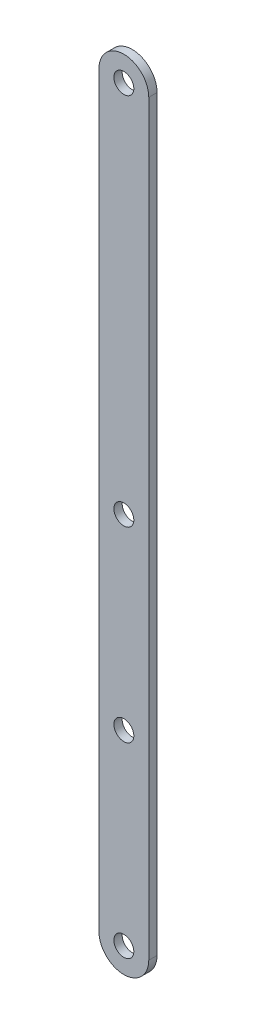
from build123d import *

# Parameters (mm, degrees)
SKETCH_1_R      = 6
EXTRUDE_1_DEPTH = 5


with BuildPart() as part:
    # 草图1 → 凸台-拉伸1 (new body)
    with BuildSketch(Plane.XY):
        with BuildLine():
            Line((8.363113875, 62.695768031), (8.363113875, 512.695768031))
            ThreePointArc((8.363113875, 512.695768031), (23.363113875, 527.695768031), (38.363113875, 512.695768031))
            Line((38.363113875, 512.695768031), (38.363113875, 62.695768031))
            ThreePointArc((38.363113875, 62.695768031), (23.363113875, 47.695768031), (8.363113875, 62.695768031))
        make_face()
        with Locations((23.363113875, 512.695768031)):
            Circle(SKETCH_1_R, mode=Mode.SUBTRACT)
        with Locations((23.363113875, 62.695768031)):
            Circle(SKETCH_1_R, mode=Mode.SUBTRACT)
        with Locations((23.363113875, 287.695768031)):
            Circle(SKETCH_1_R, mode=Mode.SUBTRACT)
        with Locations((23.363113875, 175.195768031)):
            Circle(SKETCH_1_R, mode=Mode.SUBTRACT)
    extrude(amount=EXTRUDE_1_DEPTH)


solid = part.part
